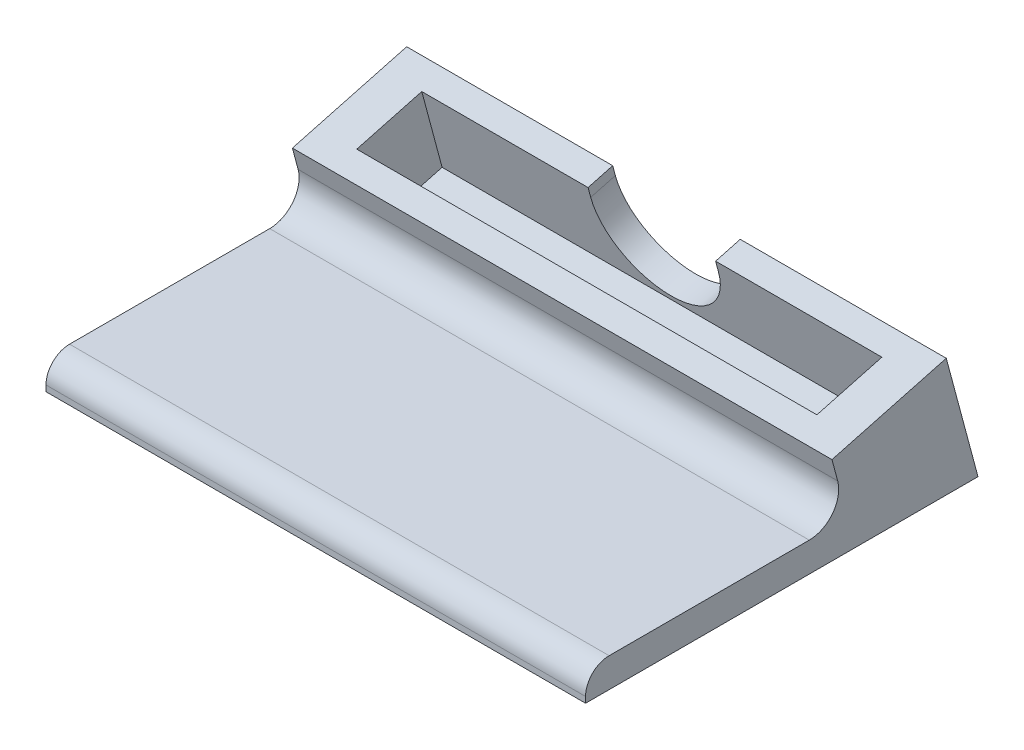
from build123d import *

# Parameters (mm, degrees)
SKETCH1_W              = 69.85
SKETCH1_H              = 50.8
BASE_DEPTH             = 3.81
PHONE_SUPPORT_DEPTH    = 69.85
FRONT_FACE_CUT_DEPTH   = 88.719987912
SKETCH4_W              = 59.563
SKETCH4_H              = 8.7122
PHONE_SLOT_DEPTH       = 10.16
HOME_BUTTON_HOLE_REACH = 87.363
FILLET1_R              = 3.81
FILLET2_R              = 3.048


with BuildPart() as part:
    # Sketch1 → Base (new body)
    with BuildSketch(Plane(origin=(0, 0, 0), x_dir=(1, 0, 0), z_dir=(0, 1, 0))):
        with Locations((34.925, 25.4)):
            Rectangle(SKETCH1_W, SKETCH1_H)
    extrude(amount=BASE_DEPTH)

    # Sketch2 → Phone support (add, through all)
    with BuildSketch(Plane(origin=(69.85, 0, 0), x_dir=(0, 0, -1), z_dir=(1, 0, 0))):
        Polygon((33.922616542, 3.81), (49.779113577, 3.81), (46.691247659, 15.334072492), (31.896934518, 11.369948234), align=None)
    extrude(amount=-PHONE_SUPPORT_DEPTH)

    # Sketch3 → Front face cut (cut, through all)
    with BuildSketch(Plane(origin=(69.85, 0, 0), x_dir=(0, 0, -1), z_dir=(1, 0, 0))):
        Polygon((50.8, 0), (49.779113577, 3.81), (50.8, 3.81), align=None)
    extrude(amount=-FRONT_FACE_CUT_DEPTH, mode=Mode.SUBTRACT)

    # Sketch4 → Phone slot (cut)
    with BuildSketch(Plane(origin=(0, 2.634072492, 0.705797597), x_dir=(1, 0, 0), z_dir=(0, 0.96592582628907, 0.2588190451025147))):
        with Locations((34.925, 41.410931975)):
            Rectangle(SKETCH4_W, SKETCH4_H)
    extrude(amount=-PHONE_SLOT_DEPTH, mode=Mode.SUBTRACT)

    # Sketch5 → Home button hole (cut, up to next)
    with BuildSketch(Plane(origin=(0, 12.7, -47.397045256), x_dir=(-1, 0, 0), z_dir=(0, 0.2588190451025147, -0.96592582628907)), mode=Mode.PRIVATE) as home_button_hole_sk1:
        with BuildLine():
            ThreePointArc((-43.17999875, 1.406192509), (-40.762165229, -4.43097397), (-34.92499875, -6.848807491))
            Line((-34.92499875, -6.848807491), (-34.92499875, 1.406192509))
            Line((-34.92499875, 1.406192509), (-43.17999875, 1.406192509))
        make_face()
    home_button_hole_tool1 = extrude(home_button_hole_sk1.sketch, amount=-HOME_BUTTON_HOLE_REACH, mode=Mode.PRIVATE) & part.part
    # Sketch5 → Home button hole (cut, up to next)
    with BuildSketch(Plane(origin=(0, 12.7, -47.397045256), x_dir=(-1, 0, 0), z_dir=(0, 0.2588190451025147, -0.96592582628907)), mode=Mode.PRIVATE) as home_button_hole_sk2:
        with BuildLine():
            Line((-34.92499875, 1.406192509), (-34.92499875, -6.848807491))
            ThreePointArc((-34.92499875, -6.848807491), (-29.087832271, -4.43097397), (-26.66999875, 1.406192509))
            Line((-26.66999875, 1.406192509), (-34.92499875, 1.406192509))
        make_face()
    home_button_hole_tool2 = extrude(home_button_hole_sk2.sketch, amount=-HOME_BUTTON_HOLE_REACH, mode=Mode.PRIVATE) & part.part
    # Sketch5 → Home button hole (cut, up to next)
    with BuildSketch(Plane(origin=(0, 12.7, -47.397045256), x_dir=(-1, 0, 0), z_dir=(0, 0.2588190451025147, -0.96592582628907)), mode=Mode.PRIVATE) as home_button_hole_sk3:
        with BuildLine():
            ThreePointArc((-43.17999875, 1.406192509), (-40.762165229, -4.43097397), (-34.92499875, -6.848807491))
            Line((-34.92499875, -6.848807491), (-34.92499875, 1.406192509))
            Line((-34.92499875, 1.406192509), (-43.17999875, 1.406192509))
        make_face()
    home_button_hole_tool3 = extrude(home_button_hole_sk3.sketch, amount=-HOME_BUTTON_HOLE_REACH, mode=Mode.PRIVATE) & part.part
    # Sketch5 → Home button hole (cut, up to next)
    with BuildSketch(Plane(origin=(0, 12.7, -47.397045256), x_dir=(-1, 0, 0), z_dir=(0, 0.2588190451025147, -0.96592582628907)), mode=Mode.PRIVATE) as home_button_hole_sk4:
        with BuildLine():
            Line((-34.92499875, 1.406192509), (-34.92499875, -6.848807491))
            ThreePointArc((-34.92499875, -6.848807491), (-29.087832271, -4.43097397), (-26.66999875, 1.406192509))
            Line((-26.66999875, 1.406192509), (-34.92499875, 1.406192509))
        make_face()
    home_button_hole_tool4 = extrude(home_button_hole_sk4.sketch, amount=-HOME_BUTTON_HOLE_REACH, mode=Mode.PRIVATE) & part.part
    # Sketch5 → Home button hole (cut, up to next)
    with BuildSketch(Plane(origin=(0, 12.7, -47.397045256), x_dir=(-1, 0, 0), z_dir=(0, 0.2588190451025147, -0.96592582628907)), mode=Mode.PRIVATE) as home_button_hole_sk5:
        with BuildLine():
            Line((-43.17999875, 1.406192509), (-34.92499875, 1.406192509))
            Line((-34.92499875, 1.406192509), (-34.92499875, 2.726992509))
            Line((-34.92499875, 2.726992509), (-43.073649703, 2.726992509))
            ThreePointArc((-43.073649703, 2.726992509), (-43.153368534, 2.068729821), (-43.17999875, 1.406192509))
        make_face()
    home_button_hole_tool5 = extrude(home_button_hole_sk5.sketch, amount=-HOME_BUTTON_HOLE_REACH, mode=Mode.PRIVATE) & part.part
    # Sketch5 → Home button hole (cut, up to next)
    with BuildSketch(Plane(origin=(0, 12.7, -47.397045256), x_dir=(-1, 0, 0), z_dir=(0, 0.2588190451025147, -0.96592582628907)), mode=Mode.PRIVATE) as home_button_hole_sk6:
        with BuildLine():
            Line((-34.92499875, 2.726992509), (-34.92499875, 1.406192509))
            Line((-34.92499875, 1.406192509), (-26.66999875, 1.406192509))
            ThreePointArc((-26.66999875, 1.406192509), (-26.696628966, 2.068729821), (-26.776347797, 2.726992509))
            Line((-26.776347797, 2.726992509), (-34.92499875, 2.726992509))
        make_face()
    home_button_hole_tool6 = extrude(home_button_hole_sk6.sketch, amount=-HOME_BUTTON_HOLE_REACH, mode=Mode.PRIVATE) & part.part
    # Sketch5 → Home button hole (cut, up to next)
    with BuildSketch(Plane(origin=(0, 12.7, -47.397045256), x_dir=(-1, 0, 0), z_dir=(0, 0.2588190451025147, -0.96592582628907)), mode=Mode.PRIVATE) as home_button_hole_sk7:
        with BuildLine():
            Line((-43.17999875, 1.406192509), (-34.92499875, 1.406192509))
            Line((-34.92499875, 1.406192509), (-34.92499875, 2.726992509))
            Line((-34.92499875, 2.726992509), (-43.073649703, 2.726992509))
            ThreePointArc((-43.073649703, 2.726992509), (-43.153368534, 2.068729821), (-43.17999875, 1.406192509))
        make_face()
    home_button_hole_tool7 = extrude(home_button_hole_sk7.sketch, amount=-HOME_BUTTON_HOLE_REACH, mode=Mode.PRIVATE) & part.part
    # Sketch5 → Home button hole (cut, up to next)
    with BuildSketch(Plane(origin=(0, 12.7, -47.397045256), x_dir=(-1, 0, 0), z_dir=(0, 0.2588190451025147, -0.96592582628907)), mode=Mode.PRIVATE) as home_button_hole_sk8:
        with BuildLine():
            Line((-34.92499875, 2.726992509), (-34.92499875, 1.406192509))
            Line((-34.92499875, 1.406192509), (-26.66999875, 1.406192509))
            ThreePointArc((-26.66999875, 1.406192509), (-26.696628966, 2.068729821), (-26.776347797, 2.726992509))
            Line((-26.776347797, 2.726992509), (-34.92499875, 2.726992509))
        make_face()
    home_button_hole_tool8 = extrude(home_button_hole_sk8.sketch, amount=-HOME_BUTTON_HOLE_REACH, mode=Mode.PRIVATE) & part.part
    # Sketch5 → Home button hole (cut, up to next)
    with BuildSketch(Plane(origin=(0, 12.7, -47.397045256), x_dir=(-1, 0, 0), z_dir=(0, 0.2588190451025147, -0.96592582628907)), mode=Mode.PRIVATE) as home_button_hole_sk9:
        with BuildLine():
            Line((-43.17999875, 2.726992509), (-43.17999875, 1.406192509))
            ThreePointArc((-43.17999875, 1.406192509), (-43.153368534, 2.068729821), (-43.073649703, 2.726992509))
            Line((-43.073649703, 2.726992509), (-43.17999875, 2.726992509))
        make_face()
    home_button_hole_tool9 = extrude(home_button_hole_sk9.sketch, amount=-HOME_BUTTON_HOLE_REACH, mode=Mode.PRIVATE) & part.part
    # Sketch5 → Home button hole (cut, up to next)
    with BuildSketch(Plane(origin=(0, 12.7, -47.397045256), x_dir=(-1, 0, 0), z_dir=(0, 0.2588190451025147, -0.96592582628907)), mode=Mode.PRIVATE) as home_button_hole_sk10:
        with BuildLine():
            ThreePointArc((-26.776347797, 2.726992509), (-26.696628966, 2.068729821), (-26.66999875, 1.406192509))
            Line((-26.66999875, 1.406192509), (-26.66999875, 2.726992509))
            Line((-26.66999875, 2.726992509), (-26.776347797, 2.726992509))
        make_face()
    home_button_hole_tool10 = extrude(home_button_hole_sk10.sketch, amount=-HOME_BUTTON_HOLE_REACH, mode=Mode.PRIVATE) & part.part
    add(home_button_hole_tool1.solids().sort_by_distance((38.42853, 10.674127, -47.939876))[0], mode=Mode.SUBTRACT)
    add(home_button_hole_tool2.solids().sort_by_distance((31.421468, 10.674127, -47.939876))[0], mode=Mode.SUBTRACT)
    add(home_button_hole_tool3.solids().sort_by_distance((38.42853, 10.674127, -47.939876))[0], mode=Mode.SUBTRACT)
    add(home_button_hole_tool4.solids().sort_by_distance((31.421468, 10.674127, -47.939876))[0], mode=Mode.SUBTRACT)
    add(home_button_hole_tool5.solids().sort_by_distance((39.034881, 14.694801, -46.86254))[0], mode=Mode.SUBTRACT)
    add(home_button_hole_tool6.solids().sort_by_distance((30.815117, 14.694801, -46.86254))[0], mode=Mode.SUBTRACT)
    add(home_button_hole_tool7.solids().sort_by_distance((39.034881, 14.694801, -46.86254))[0], mode=Mode.SUBTRACT)
    add(home_button_hole_tool8.solids().sort_by_distance((30.815117, 14.694801, -46.86254))[0], mode=Mode.SUBTRACT)
    add(home_button_hole_tool9.solids().sort_by_distance((43.14813, 15.015536, -46.776599))[0], mode=Mode.SUBTRACT)
    add(home_button_hole_tool10.solids().sort_by_distance((26.701868, 15.015536, -46.776599))[0], mode=Mode.SUBTRACT)

    # Fillet1
    fillet1_edges = [part.edges().sort_by_distance(p)[0] for p in [
        (34.925, 3.81, -33.922616542),
    ]]
    fillet(fillet1_edges, radius=FILLET1_R)

    # Fillet2
    fillet2_edges = [part.edges().sort_by_distance(p)[0] for p in [
        (34.925, 3.81, 0),
    ]]
    fillet(fillet2_edges, radius=FILLET2_R)


solid = part.part
